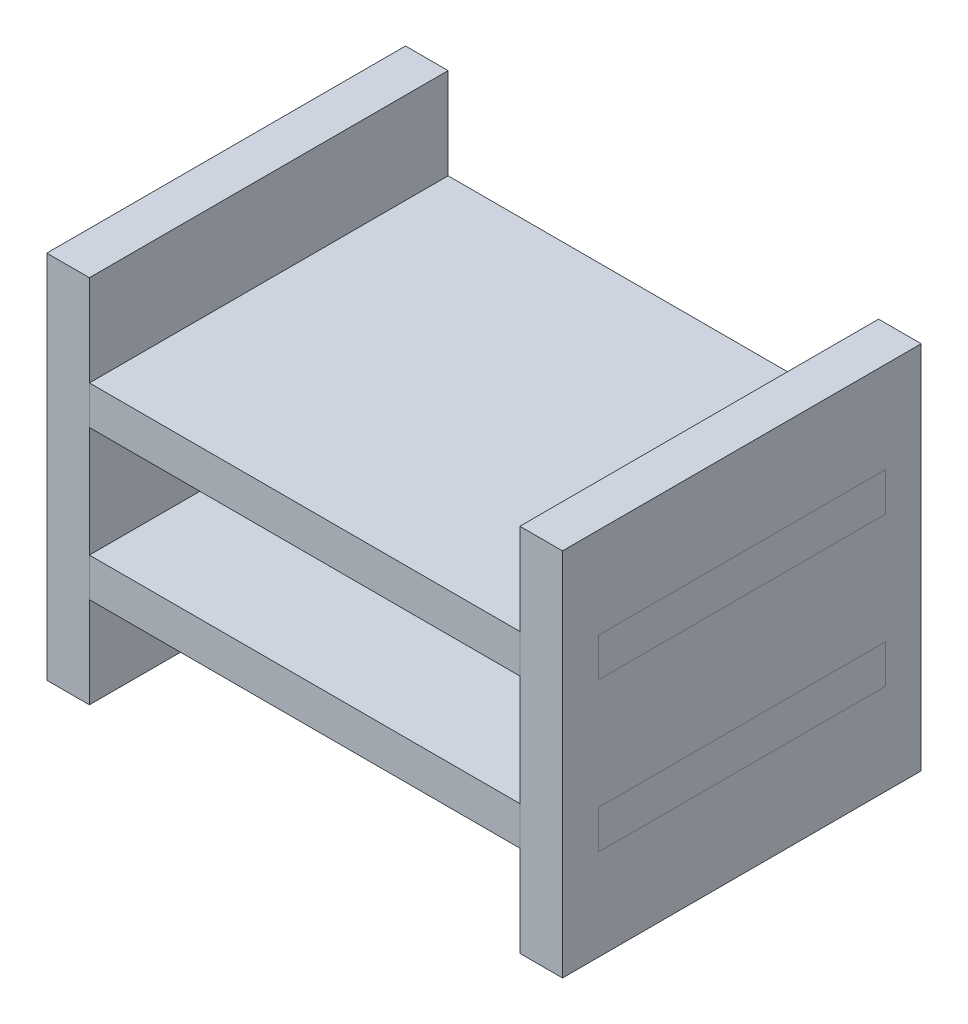
from build123d import *

# Parameters (mm, degrees)
SKETCH2_W           = 30
SKETCH2_H           = 25
SKETCH2_W_2         = 2.97
SKETCH2_H_2         = 20
BOSS_EXTRUDE3_DEPTH = 2.69
BOSS_EXTRUDE4_START = 10.39
SKETCH2_3_W         = 2.97
SKETCH2_3_H         = 20
SKETCH2_3_W_2       = 30
SKETCH2_3_H_2       = 25
BOSS_EXTRUDE4_DEPTH = 2.69
SKETCH4_W           = 25
SKETCH4_H           = 25.78
SKETCH4_W_2         = 20
SKETCH4_H_2         = 2.69
BOSS_EXTRUDE5_DEPTH = 2.97


with BuildPart() as part:
    # Sketch2 → Boss-Extrude3 (new body)
    with BuildSketch(Plane(origin=(0, 0, 0), x_dir=(1, 0, 0), z_dir=(0, 1, 0))):
        Rectangle(SKETCH2_W, SKETCH2_H)
        with Locations((-16.485, 0)):
            Rectangle(SKETCH2_W_2, SKETCH2_H_2)
        with Locations((16.485, 0)):
            Rectangle(SKETCH2_W_2, SKETCH2_H_2)
    extrude(amount=BOSS_EXTRUDE3_DEPTH)


with BuildPart() as body_2:
    # Sketch2_3 → Boss-Extrude4 (new body)
    with BuildSketch(Plane(origin=(0, 0, 0), x_dir=(1, 0, 0), z_dir=(0, 1, 0)).offset(BOSS_EXTRUDE4_START)):
        with Locations((-16.485, 0)):
            Rectangle(SKETCH2_3_W, SKETCH2_3_H)
        Rectangle(SKETCH2_3_W_2, SKETCH2_3_H_2)
        with Locations((16.485, 0)):
            Rectangle(SKETCH2_3_W, SKETCH2_3_H)
    extrude(amount=BOSS_EXTRUDE4_DEPTH)


with BuildPart() as body_3:
    # Sketch4 → Boss-Extrude5 (new body)
    with BuildSketch(Plane(origin=(15, 0, 0), x_dir=(0, 0, -1), z_dir=(1, 0, 0))):
        with Locations((0, 6.54)):
            Rectangle(SKETCH4_W, SKETCH4_H)
        with Locations((0, 11.735)):
            Rectangle(SKETCH4_W_2, SKETCH4_H_2, mode=Mode.SUBTRACT)
        with Locations((0, 1.345)):
            Rectangle(SKETCH4_W_2, SKETCH4_H_2, mode=Mode.SUBTRACT)
    extrude(amount=BOSS_EXTRUDE5_DEPTH)


with BuildPart() as body_4:
    # Mirror1: mirrored copy
    add(body_3.part.mirror(Plane(origin=(0, 0, 0), x_dir=(0, 0, 1), z_dir=(1, 0, 0))))


solid = Compound([part.part, body_2.part, body_3.part, body_4.part])
